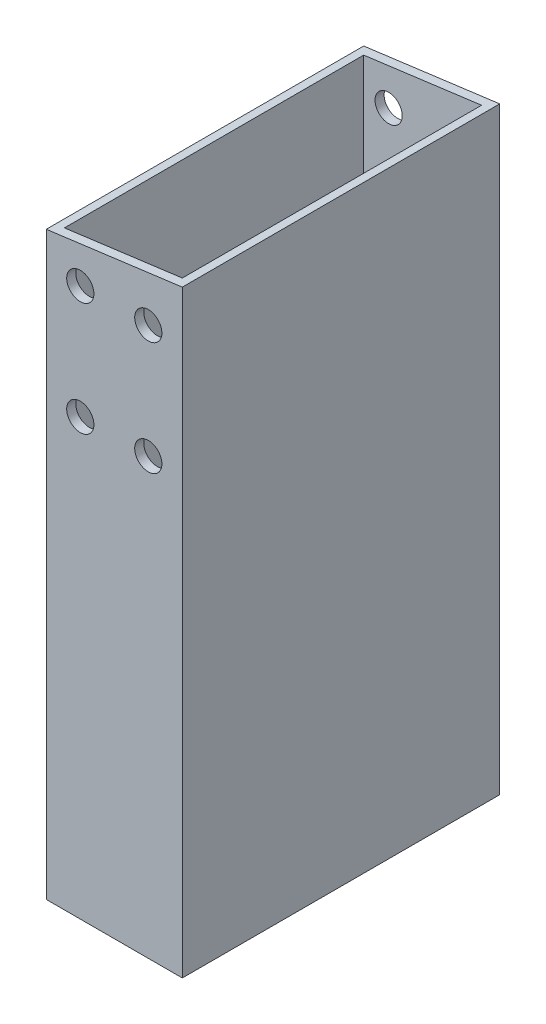
from build123d import *

# Parameters (mm, degrees)
SKETCH_1_W          = 30
SKETCH_1_H          = 750
SKETCH_1_R          = 2.000000003
SKETCH_1_R_2        = 2.000000001
EXTRUDE_2_DEPTH     = 70
SKETCH_2_W          = 26
SKETCH_2_H          = 66
CUT_EXTRUDE_3_DEPTH = 751
CUT_EXTRUDE_4_DEPTH = 71
SKETCH_4_W          = 30
SKETCH_4_H          = 922.920510985
CUT_EXTRUDE_5_DEPTH = 71
SKETCH_5_R          = 3
CUT_EXTRUDE_6_DEPTH = 91


with BuildPart() as part:
    # 草图1 → 凸台-拉伸2 (new body)
    with BuildSketch(Plane.XY):
        Rectangle(SKETCH_1_W, SKETCH_1_H)
        with Locations((-7.5, 363.96878712)):
            Circle(SKETCH_1_R, mode=Mode.SUBTRACT)
        with Locations((7.5, 363.96878712)):
            Circle(SKETCH_1_R, mode=Mode.SUBTRACT)
        with Locations((-7.5, 338.96878712)):
            Circle(SKETCH_1_R, mode=Mode.SUBTRACT)
        with Locations((7.5, 338.96878712)):
            Circle(SKETCH_1_R, mode=Mode.SUBTRACT)
        with Locations((-7.5, -312.867936975)):
            Circle(SKETCH_1_R_2, mode=Mode.SUBTRACT)
        with Locations((7.5, -312.867936975)):
            Circle(SKETCH_1_R_2, mode=Mode.SUBTRACT)
        with Locations((-7.5, -337.867936975)):
            Circle(SKETCH_1_R_2, mode=Mode.SUBTRACT)
        with Locations((7.5, -337.867936975)):
            Circle(SKETCH_1_R_2, mode=Mode.SUBTRACT)
    extrude(amount=EXTRUDE_2_DEPTH)

    # 草图2 → 切除-拉伸3 (cut, through all)
    with BuildSketch(Plane.XZ.offset(375)):
        with Locations((0, 35)):
            Rectangle(SKETCH_2_W, SKETCH_2_H)
    extrude(amount=-CUT_EXTRUDE_3_DEPTH, mode=Mode.SUBTRACT)

    # 草图3 → 切除-拉伸4 (cut, through all)
    with BuildSketch(Plane.XY.offset(70)):
        Polygon((15, -375), (15, -347.1), (-15, -343.150425072), (-15, -375), align=None)
        Polygon((15, 377.040830045), (15, 375), (-15, 371.050425072), (-15, 377.040830045), align=None)
    extrude(amount=-CUT_EXTRUDE_4_DEPTH, mode=Mode.SUBTRACT)

    # 草图4 → 切除-拉伸5 (cut, through all)
    with BuildSketch(Plane(origin=(0, 0, 0), x_dir=(-1, 0, 0), z_dir=(0, 0, -1))):
        with Locations((0, -218.40983042)):
            Rectangle(SKETCH_4_W, SKETCH_4_H)
    extrude(amount=-CUT_EXTRUDE_5_DEPTH, mode=Mode.SUBTRACT)

    # 草图5 → 切除-拉伸6 (cut)
    with BuildSketch(Plane.XY.offset(70)):
        with Locations((-7.5, 363.96878712)):
            Circle(SKETCH_5_R)
        with Locations((7.5, 363.96878712)):
            Circle(SKETCH_5_R)
        with Locations((7.5, 338.96878712)):
            Circle(SKETCH_5_R)
        with Locations((-7.5, 338.96878712)):
            Circle(SKETCH_5_R)
    extrude(amount=-CUT_EXTRUDE_6_DEPTH, mode=Mode.SUBTRACT)


solid = part.part
